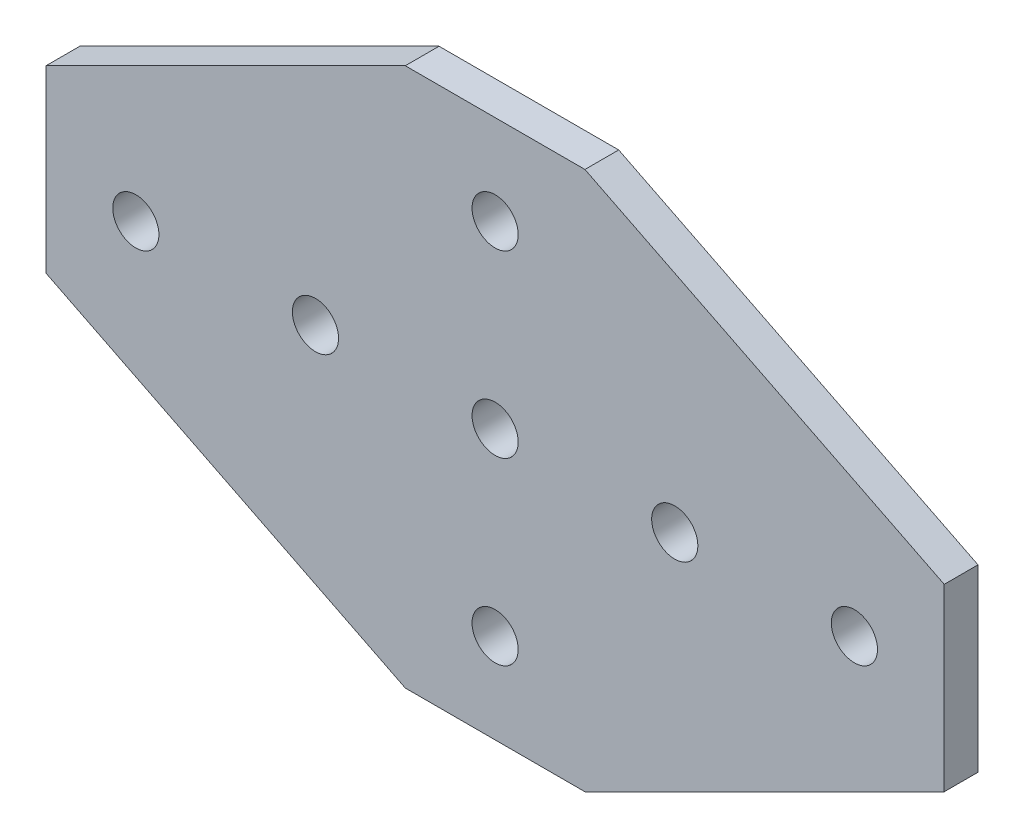
from build123d import *

# Parameters (mm, degrees)
BASE_EXTRUDE_DEPTH  = 4.7752
SKETCH2_R           = 3.2639
HOLE1_DEPTH         = 5.7752
HOLE1_PATTERN_COUNT = 5
HOLE1_PATTERN_PITCH = 25.4
SKETCH3_R           = 3.2639
HOLE2_DEPTH         = 5.7752
HOLE2_PATTERN_COUNT = 2
HOLE2_PATTERN_PITCH = 50.8


with BuildPart() as part:
    # Sketch1 → Base Extrude (new body)
    with BuildSketch(Plane.XY):
        Polygon((50.8, 0), (76.2, 0), (127, 25.4), (127, 50.8), (76.2, 76.2), (50.8, 76.2), (0, 50.8), (0, 25.4), align=None)
    extrude(amount=BASE_EXTRUDE_DEPTH)

    # Sketch2 → Hole1 (cut, through all)
    with BuildSketch(Plane.XY.offset(4.7752)):
        with Locations((12.7, 38.1)):
            Circle(SKETCH2_R)
    hole1 = extrude(amount=-HOLE1_DEPTH, mode=Mode.SUBTRACT)

    # Hole1 Pattern: Hole1 ×5
    with Locations(*[(i * HOLE1_PATTERN_PITCH, 0, 0) for i in range(1, HOLE1_PATTERN_COUNT)]):
        add(hole1, mode=Mode.SUBTRACT)

    # Sketch3 → Hole2 (cut, through all)
    with BuildSketch(Plane.XY.offset(4.7752)):
        with Locations((63.5, 12.7)):
            Circle(SKETCH3_R)
    hole2 = extrude(amount=-HOLE2_DEPTH, mode=Mode.SUBTRACT)

    # Hole2 Pattern: Hole2 ×2
    with Locations(*[(0, i * HOLE2_PATTERN_PITCH, 0) for i in range(1, HOLE2_PATTERN_COUNT)]):
        add(hole2, mode=Mode.SUBTRACT)


solid = part.part
